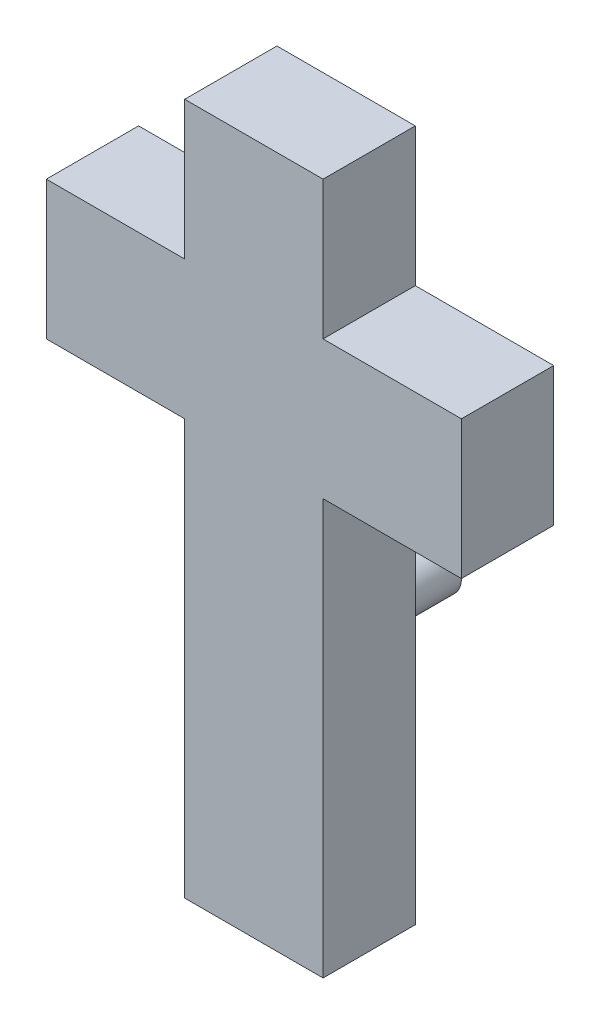
from build123d import *

# Parameters (mm, degrees)
BOSS_EXTRUDE1_DEPTH = 5.08
SKETCH2_R           = 1.27
BOSS_EXTRUDE2_DEPTH = 5.08


with BuildPart() as part:
    # Sketch1 → Boss-Extrude1 (new body)
    with BuildSketch(Plane.XY):
        Polygon((0, 0), (0, 22.86), (-7.62, 22.86), (-7.62, 30.48), (0, 30.48), (0, 38.1), (7.62, 38.1), (7.62, 30.48), (15.24, 30.48), (15.24, 22.86), (7.62, 22.86), (7.62, 0), align=None)
    extrude(amount=BOSS_EXTRUDE1_DEPTH)

    # Sketch2 → Boss-Extrude2 (add)
    with BuildSketch(Plane(origin=(0, 0, 0), x_dir=(-1, 0, 0), z_dir=(0, 0, -1))):
        with Locations((-3.81, 20.32)):
            Circle(SKETCH2_R)
        with Locations((-3.81, 12.7)):
            Circle(SKETCH2_R)
    extrude(amount=BOSS_EXTRUDE2_DEPTH)


solid = part.part
